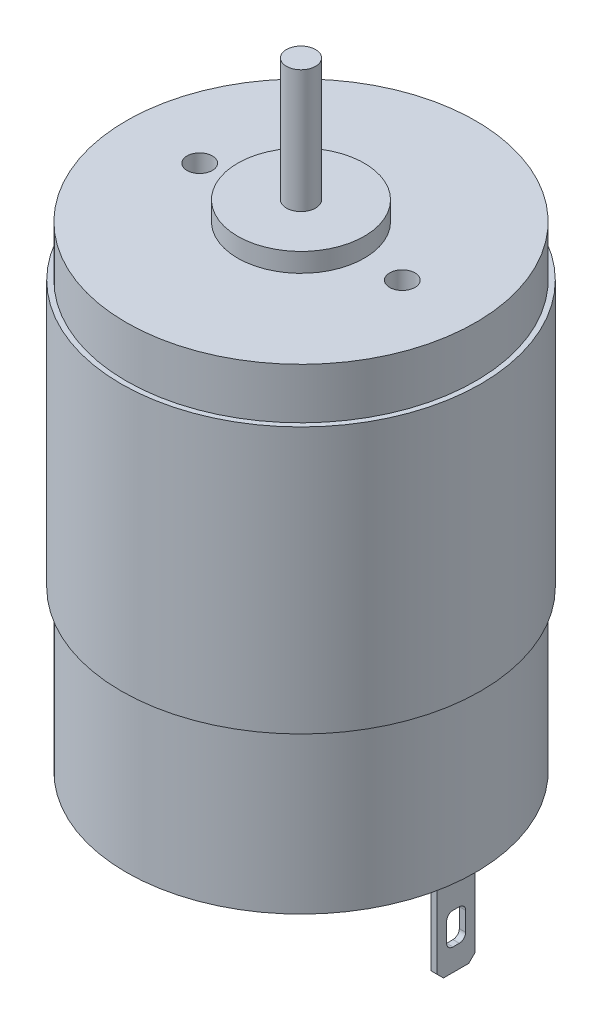
from build123d import *

# Parameters (mm, degrees)
SKETCH1_R           = 13.8
BOSS_EXTRUDE1_DEPTH = 37.6
SKETCH2_R           = 5
BOSS_EXTRUDE2_DEPTH = 1.5
SKETCH3_R           = 1.15
BOSS_EXTRUDE3_DEPTH = 9.7
SKETCH4_R           = 1
CUT_EXTRUDE1_DEPTH  = 5
SKETCH5_R           = 5
BOSS_EXTRUDE4_DEPTH = 2.5
SKETCH6_W           = 0.5
SKETCH6_H           = 3
BOSS_EXTRUDE5_DEPTH = 7.5
SKETCH7_W           = 1.5
SKETCH7_H           = 2.5
CUT_EXTRUDE2_DEPTH  = 24.5
CHAMFER1_SIZE       = 0.5
FILLET1_R           = 0.5
SKETCH8_R           = 14.2
SKETCH8_R_2         = 13.8
BOSS_EXTRUDE6_DEPTH = 21


with BuildPart() as part:
    # Sketch1 → Boss-Extrude1 (new body)
    with BuildSketch(Plane(origin=(0, 0, 0), x_dir=(1, 0, 0), z_dir=(0, 1, 0))):
        Circle(SKETCH1_R)
    extrude(amount=BOSS_EXTRUDE1_DEPTH)

    # Sketch2 → Boss-Extrude2 (add)
    with BuildSketch(Plane(origin=(0, 37.6, 0), x_dir=(1, 0, 0), z_dir=(0, 1, 0))):
        Circle(SKETCH2_R)
    extrude(amount=BOSS_EXTRUDE2_DEPTH)

    # Sketch3 → Boss-Extrude3 (add)
    with BuildSketch(Plane(origin=(0, 39.1, 0), x_dir=(1, 0, 0), z_dir=(0, 1, 0))):
        Circle(SKETCH3_R)
    extrude(amount=BOSS_EXTRUDE3_DEPTH)

    # Sketch4 → Cut-Extrude1 (cut)
    with BuildSketch(Plane(origin=(0, 37.6, 0), x_dir=(1, 0, 0), z_dir=(0, 1, 0))):
        with Locations((8, 0)):
            Circle(SKETCH4_R)
        with Locations((-8, 0)):
            Circle(SKETCH4_R)
    extrude(amount=-CUT_EXTRUDE1_DEPTH, mode=Mode.SUBTRACT)

    # Sketch5 → Boss-Extrude4 (add)
    with BuildSketch(Plane.XZ):
        Circle(SKETCH5_R)
    extrude(amount=BOSS_EXTRUDE4_DEPTH)

    # Sketch6 → Boss-Extrude5 (add)
    with BuildSketch(Plane.XZ):
        with Locations((12, 0)):
            Rectangle(SKETCH6_W, SKETCH6_H)
        with Locations((-12, 0)):
            Rectangle(SKETCH6_W, SKETCH6_H)
    extrude(amount=BOSS_EXTRUDE5_DEPTH)

    # Sketch7 → Cut-Extrude2 (cut)
    with BuildSketch(Plane(origin=(12.25, 0, 0), x_dir=(0, 0, -1), z_dir=(1, 0, 0))):
        with Locations((0, -4.5)):
            Rectangle(SKETCH7_W, SKETCH7_H)
    extrude(amount=-CUT_EXTRUDE2_DEPTH, mode=Mode.SUBTRACT)

    # Chamfer1
    chamfer1_edges = [part.edges().sort_by_distance(p)[0] for p in [
        (12, -7.5, 1.5),
        (12, -7.5, -1.5),
        (-12, -7.5, 1.5),
        (-12, -7.5, -1.5),
    ]]
    chamfer(chamfer1_edges, length=CHAMFER1_SIZE)

    # Fillet1
    fillet1_edges = [part.edges().sort_by_distance(p)[0] for p in [
        (12, -3.25, -0.75),
        (-12, -3.25, -0.75),
        (12, -5.75, -0.75),
        (-12, -5.75, -0.75),
        (12, -5.75, 0.75),
        (-12, -5.75, 0.75),
        (12, -3.25, 0.75),
        (-12, -3.25, 0.75),
    ]]
    fillet(fillet1_edges, radius=FILLET1_R)

    # Sketch8 → Boss-Extrude6 (add)
    with BuildSketch(Plane(origin=(0, 33.6, 0), x_dir=(1, 0, 0), z_dir=(0, 1, 0))):
        Circle(SKETCH8_R)
        Circle(SKETCH8_R_2, mode=Mode.SUBTRACT)
    extrude(amount=-BOSS_EXTRUDE6_DEPTH)


solid = part.part
